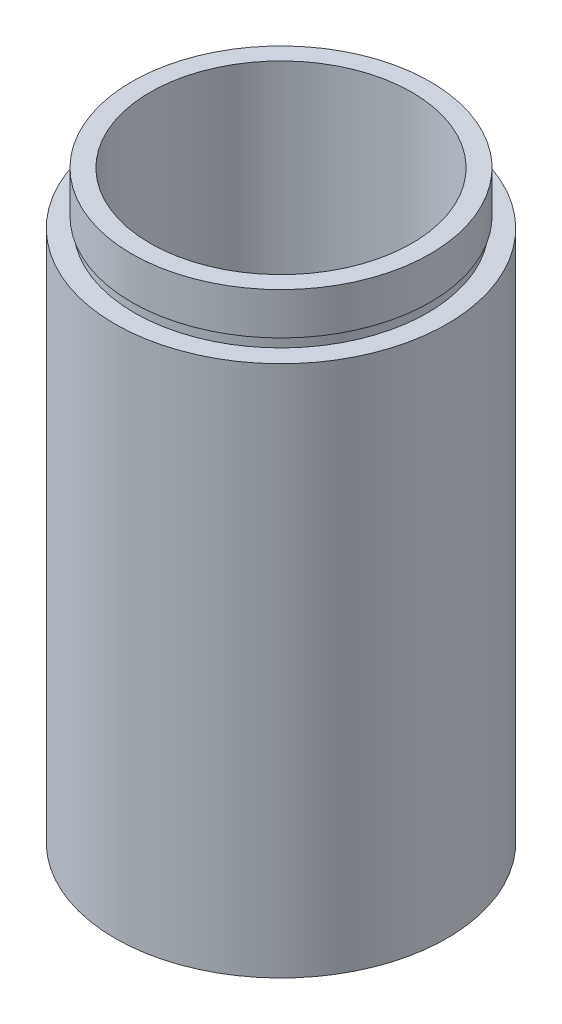
from build123d import *


with BuildPart() as part:
    # 草图1 → 旋转1 (revolve)
    with BuildSketch(Plane.XY, mode=Mode.PRIVATE) as revolve_1_sk:
        Polygon((14.25, 0), (14.25, 4.5), (14.35, 4.5), (14.35, 5.5), (12.5, 5.5), (12.5, 55.8), (14.25, 55.8), (14.25, 51.8), (14, 51.8), (14, 50.8), (15.85, 50.8), (15.85, 0), align=None)
    revolve(revolve_1_sk.sketch.rotate(Axis((0, 161.376166943, 0), (0, -1, 0)), 90), axis=Axis((0, 161.376166943, 0), (0, -1, 0)))  # turned: the seam where the file's is


solid = part.part
